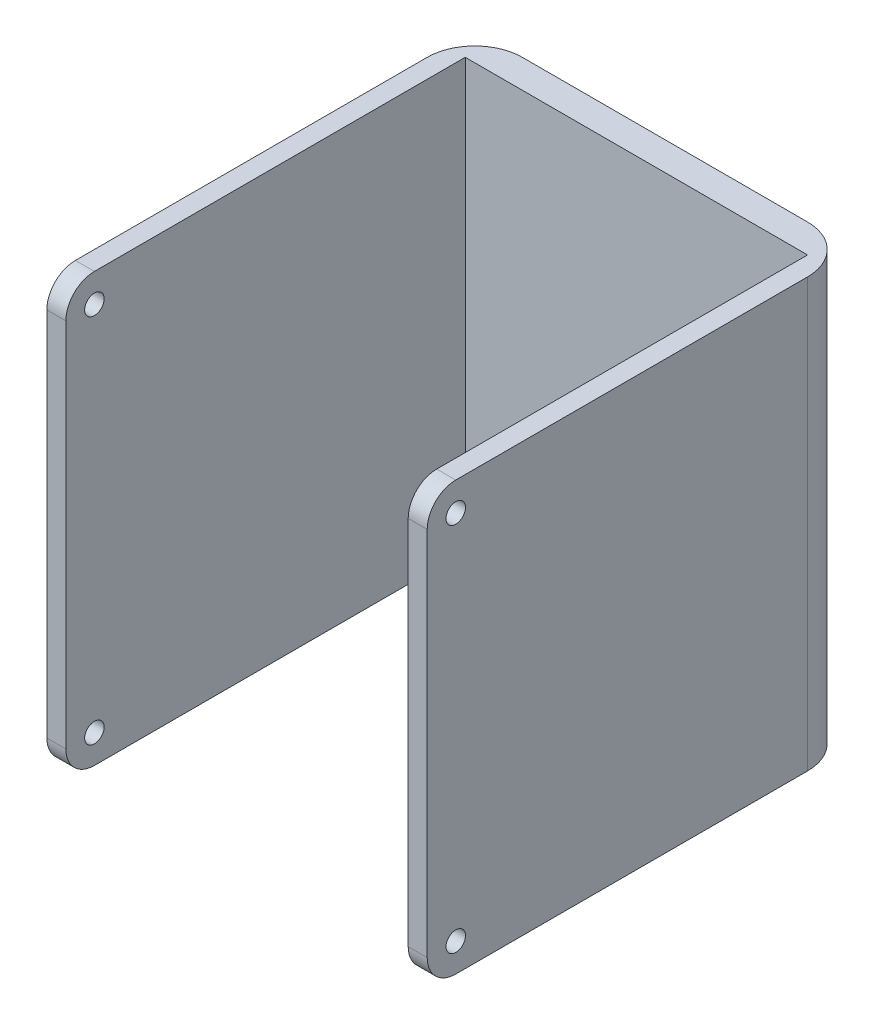
from build123d import *

# Parameters (mm, degrees)
SKETCH_1_W           = 40
SKETCH_1_H           = 45
EXTRUDE_1_DEPTH      = 40
EXTRUDE_1_DEPTH_BACK = 5
SKETCH_2_W           = 36
SKETCH_2_H           = 37
CUT_EXTRUDE_1_DEPTH  = 50
SKETCH_3_R           = 1.025
CUT_EXTRUDE_2_DEPTH  = 2
SKETCH_4_R           = 1.025
CUT_EXTRUDE_3_DEPTH  = 2
SKETCH_5_W           = 36
SKETCH_5_H           = 5
CUT_EXTRUDE_4_DEPTH  = 43
FILLET_6_R           = 5
FILLET_7_R           = 5
FILLET_12_R          = 3
FILLET_13_R          = 3
FILLET_14_R          = 3
FILLET_15_R          = 3


with BuildPart() as part:
    # 草圖1 → 填料-伸長1 (new body, two sides)
    with BuildSketch(Plane.XY) as extrude_1_sk:
        with Locations((5.454545455, -5.590909091)):
            Rectangle(SKETCH_1_W, SKETCH_1_H)
    extrude(amount=EXTRUDE_1_DEPTH)
    extrude(extrude_1_sk.sketch, amount=-EXTRUDE_1_DEPTH_BACK)

    # 草圖2 → 除料-伸長1 (cut)
    with BuildSketch(Plane(origin=(0, 16.909090909, 0), x_dir=(1, 0, 0), z_dir=(0, 1, 0))):
        with Locations((5.454545455, -21.5)):
            Rectangle(SKETCH_2_W, SKETCH_2_H)
    extrude(amount=-CUT_EXTRUDE_1_DEPTH, mode=Mode.SUBTRACT)

    # 草圖3 → 除料-伸長2 (cut)
    with BuildSketch(Plane.ZY.offset(14.545454545)):
        with Locations((37, -25.090909091)):
            Circle(SKETCH_3_R)
        with Locations((37, 13.909090909)):
            Circle(SKETCH_3_R)
    extrude(amount=-CUT_EXTRUDE_2_DEPTH, mode=Mode.SUBTRACT)

    # 草圖4 → 除料-伸長3 (cut)
    with BuildSketch(Plane(origin=(25.454545455, 0, 0), x_dir=(0, 0, -1), z_dir=(1, 0, 0))):
        with Locations((-37, 13.909090909)):
            Circle(SKETCH_4_R)
        with Locations((-37, -25.090909091)):
            Circle(SKETCH_4_R)
    extrude(amount=-CUT_EXTRUDE_3_DEPTH, mode=Mode.SUBTRACT)

    # 草圖5 → 除料-伸長4 (cut)
    with BuildSketch(Plane(origin=(0, 16.909090909, 0), x_dir=(1, 0, 0), z_dir=(0, 1, 0))):
        with Locations((5.454545455, -0.5)):
            Rectangle(SKETCH_5_W, SKETCH_5_H)
    extrude(amount=-CUT_EXTRUDE_4_DEPTH, mode=Mode.SUBTRACT)

    # 圓角6
    fillet_6_edges = [part.edges().sort_by_distance(p)[0] for p in [
        (-14.545454545, -5.590909091, -5),
    ]]
    fillet(fillet_6_edges, radius=FILLET_6_R)

    # 圓角7
    fillet_7_edges = [part.edges().sort_by_distance(p)[0] for p in [
        (25.454545455, -5.590909091, -5),
    ]]
    fillet(fillet_7_edges, radius=FILLET_7_R)

    # 圓角12
    fillet_12_edges = [part.edges().sort_by_distance(p)[0] for p in [
        (-13.545454545, -28.090909091, 40),
    ]]
    fillet(fillet_12_edges, radius=FILLET_12_R)

    # 圓角13
    fillet_13_edges = [part.edges().sort_by_distance(p)[0] for p in [
        (24.454545455, -28.090909091, 40),
    ]]
    fillet(fillet_13_edges, radius=FILLET_13_R)

    # 圓角14
    fillet_14_edges = [part.edges().sort_by_distance(p)[0] for p in [
        (-13.545454545, 16.909090909, 40),
    ]]
    fillet(fillet_14_edges, radius=FILLET_14_R)

    # 圓角15
    fillet_15_edges = [part.edges().sort_by_distance(p)[0] for p in [
        (24.454545455, 16.909090909, 40),
    ]]
    fillet(fillet_15_edges, radius=FILLET_15_R)


solid = part.part
